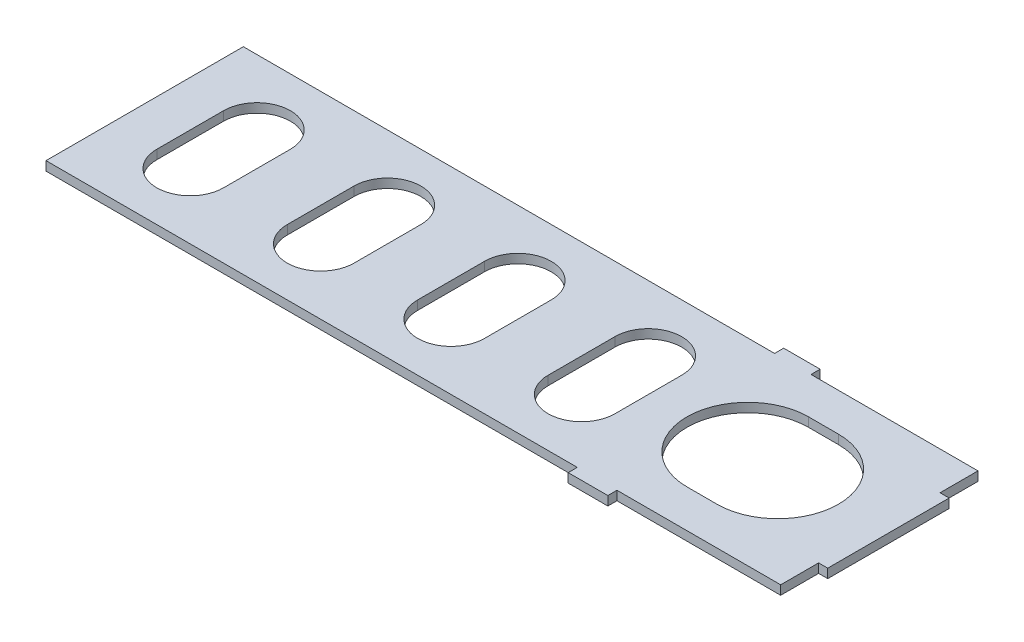
from build123d import *

# Parameters (mm, degrees)
SKETCH1_W           = 245
SKETCH1_H           = 65
BOSS_EXTRUDE1_DEPTH = 3
CUT_EXTRUDE1_DEPTH  = 10
SKETCH3_W           = 3
SKETCH3_H           = 12.5
CUT_EXTRUDE2_DEPTH  = 10
SKETCH5_W           = 12
SKETCH5_H           = 3
SKETCH5_W_2         = 13.071416553
BOSS_EXTRUDE2_DEPTH = 3


with BuildPart() as part:
    # Sketch1 → Boss-Extrude1 (new body)
    with BuildSketch(Plane(origin=(0, 0, 0), x_dir=(1, 0, 0), z_dir=(0, 1, 0))):
        Rectangle(SKETCH1_W, SKETCH1_H)
    extrude(amount=BOSS_EXTRUDE1_DEPTH)

    # Sketch2 → Cut-Extrude1 (cut)
    with BuildSketch(Plane(origin=(0, 3, 0), x_dir=(1, 0, 0), z_dir=(0, 1, 0))):
        with BuildLine():
            Line((-85.5, 11), (-85.5, -11))
            ThreePointArc((-85.5, -11), (-96.5, -22), (-107.5, -11))
            Line((-107.5, -11), (-107.5, 11))
            ThreePointArc((-107.5, 11), (-96.5, 22), (-85.5, 11))
        make_face()
        with BuildLine():
            Line((86.035837844, -20), (76.144700887, -20))
            ThreePointArc((76.144700887, -20), (56.144700887, 0), (76.144700887, 20))
            Line((76.144700887, 20), (86.035837844, 20))
            ThreePointArc((86.035837844, 20), (106.035837844, 0), (86.035837844, -20))
        make_face()
        with BuildLine():
            Line((-64.530127929, 11), (-64.530127929, -11))
            ThreePointArc((-64.530127929, -11), (-53.530127929, -22), (-42.530127929, -11))
            Line((-42.530127929, -11), (-42.530127929, 11))
            ThreePointArc((-42.530127929, 11), (-53.530127929, 22), (-64.530127929, 11))
        make_face()
        with BuildLine():
            Line((-21.560255858, 11), (-21.560255858, -11))
            ThreePointArc((-21.560255858, -11), (-10.560255858, -22), (0.439744142, -11))
            Line((0.439744142, -11), (0.439744142, 11))
            ThreePointArc((0.439744142, 11), (-10.560255858, 22), (-21.560255858, 11))
        make_face()
        with BuildLine():
            Line((21.409616214, 11), (21.409616214, -11))
            ThreePointArc((21.409616214, -11), (32.409616214, -22), (43.409616214, -11))
            Line((43.409616214, -11), (43.409616214, 11))
            ThreePointArc((43.409616214, 11), (32.409616214, 22), (21.409616214, 11))
        make_face()
    extrude(amount=-CUT_EXTRUDE1_DEPTH, mode=Mode.SUBTRACT)

    # Sketch3 → Cut-Extrude2 (cut)
    with BuildSketch(Plane(origin=(0, 3, 0), x_dir=(1, 0, 0), z_dir=(0, 1, 0))):
        with Locations((121, 26.25)):
            Rectangle(SKETCH3_W, SKETCH3_H)
        with Locations((121, -26.25)):
            Rectangle(SKETCH3_W, SKETCH3_H)
    extrude(amount=-CUT_EXTRUDE2_DEPTH, mode=Mode.SUBTRACT)

    # Sketch5 → Boss-Extrude2 (add)
    with BuildSketch(Plane(origin=(0, 3, 0), x_dir=(1, 0, 0), z_dir=(0, 1, 0))):
        with Locations((58.5, 34)):
            Rectangle(SKETCH5_W, SKETCH5_H)
        with Locations((59.035708277, -34)):
            Rectangle(SKETCH5_W_2, SKETCH5_H)
    extrude(amount=-BOSS_EXTRUDE2_DEPTH)


solid = part.part
